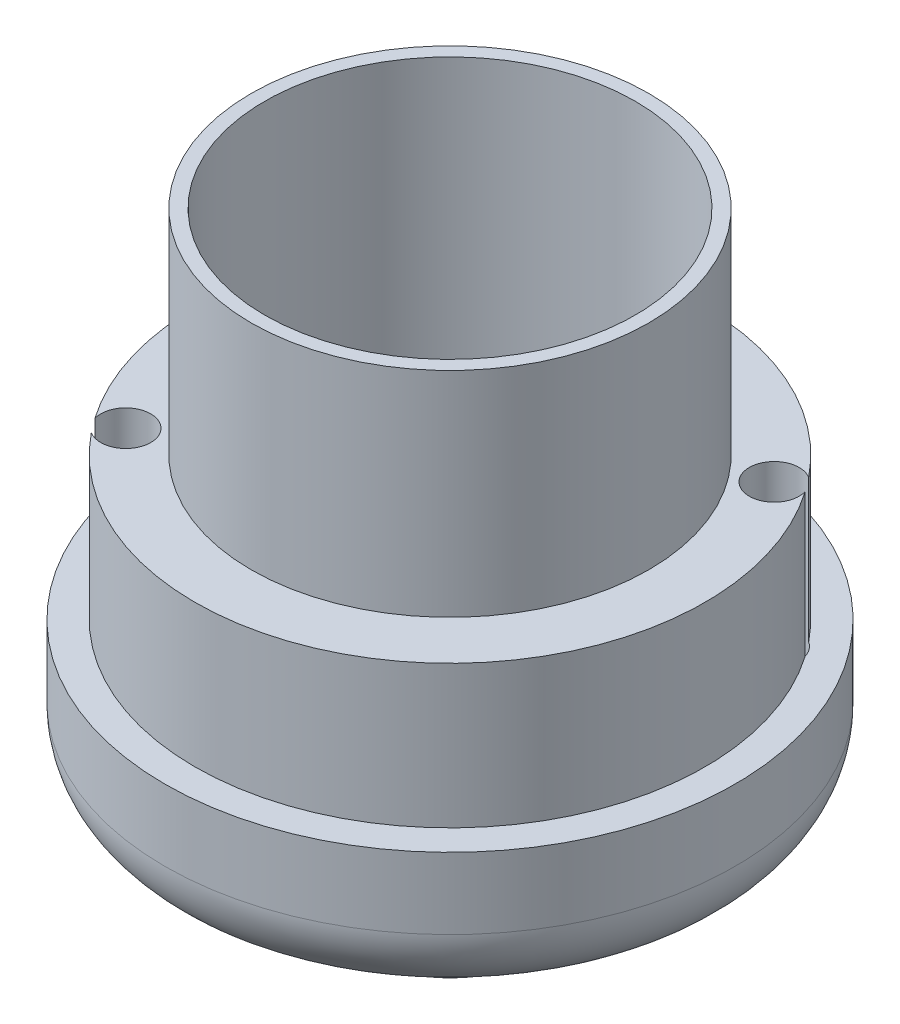
from build123d import *

# Parameters (mm, degrees)
SKETCH1_R               = 17.9
SKETCH1_R_2             = 14.9
BOSS_EXTRUDE1_DEPTH     = 10
SKETCH2_R               = 20
BOSS_EXTRUDE2_DEPTH     = 10
FILLET1_R               = 5
SKETCH3_R               = 1.75
CUT_EXTRUDE1_DEPTH      = 1
CUT_EXTRUDE1_DEPTH_BACK = 332.06387935
CUT_EXTRUDE3_DEPTH      = 3
SKETCH8_R               = 13
BOSS_EXTRUDE3_DEPTH     = 10
SKETCH9_R               = 6.05
BOSS_EXTRUDE4_DEPTH     = 7.5
FILLET2_R               = 2.5
SKETCH11_R              = 2.25
CUT_EXTRUDE4_DEPTH      = 17.5
CUT_EXTRUDE5_DEPTH      = 3.5
SKETCH13_R              = 13.95
SKETCH13_R_2            = 13
BOSS_EXTRUDE5_DEPTH     = 15


with BuildPart() as part:
    # Sketch1 → Boss-Extrude1 (new body)
    with BuildSketch(Plane(origin=(0, -62.195205507, 0), x_dir=(-1, 0, 0), z_dir=(0, -1, 0))):
        with Locations((-0.536002938, -73.600816835)):
            Circle(SKETCH1_R)
        with Locations((-0.536002938, -73.600816835)):
            Circle(SKETCH1_R_2, mode=Mode.SUBTRACT)
    extrude(amount=BOSS_EXTRUDE1_DEPTH)

    # Sketch2 → Boss-Extrude2 (add)
    with BuildSketch(Plane(origin=(0, -72.195205507, 0), x_dir=(-1, 0, 0), z_dir=(0, -1, 0))):
        with Locations((-0.536002938, -73.600816835)):
            Circle(SKETCH2_R)
    extrude(amount=BOSS_EXTRUDE2_DEPTH)

    # Fillet1
    fillet1_edges = [part.edges().sort_by_distance(p)[0] for p in [
        (20.536002938, -82.195205507, 73.600816835),
    ]]
    fillet(fillet1_edges, radius=FILLET1_R)

    # Sketch3 → Cut-Extrude1 (cut, two sides)
    with BuildSketch(Plane(origin=(0, 248.868673843, 0), x_dir=(1, 0, 0), z_dir=(0, 1, 0))) as cut_extrude1_sk:
        with Locations((-12.468535925, -83.344762082)):
            Circle(SKETCH3_R)
        with Locations((13.5405418, -63.856871588)):
            Circle(SKETCH3_R)
    extrude(amount=CUT_EXTRUDE1_DEPTH, mode=Mode.SUBTRACT)
    extrude(cut_extrude1_sk.sketch, amount=-CUT_EXTRUDE1_DEPTH_BACK, mode=Mode.SUBTRACT)

    # Sketch7 → Cut-Extrude3 (cut)
    with BuildSketch(Plane(origin=(0, -82.195205507, 0), x_dir=(-1, 0, 0), z_dir=(0, -1, 0))):
        Polygon((10.564463201, -85.88599021), (13.717267678, -86.264351495), (15.621340402, -83.723123368), (14.372608649, -80.803533955), (11.219804171, -80.425172669), (9.315731448, -82.966400796), align=None)
        Polygon((-15.444614524, -66.398099716), (-12.291810047, -66.776461002), (-10.387737323, -64.235232874), (-11.636469076, -61.315643461), (-14.789273554, -60.937282175), (-16.693346277, -63.478510303), align=None)
    extrude(amount=-CUT_EXTRUDE3_DEPTH, mode=Mode.SUBTRACT)

    # Sketch8 → Boss-Extrude3 (add)
    with BuildSketch(Plane(origin=(0, -62.195205507, 0), x_dir=(1, 0, 0), z_dir=(0, 1, 0))):
        with BuildLine():
            ThreePointArc((16.682247488, -73.600816835), (16.107712715, -69.331968315), (14.424995948, -65.36691823))
            ThreePointArc((14.424995948, -65.36691823), (12.661441741, -65.370041468), (11.790660849, -63.836459442))
            ThreePointArc((11.790660849, -63.836459442), (-8.398445319, -61.676655048), (-11.996595259, -81.659599773))
            ThreePointArc((-11.996595259, -81.659599773), (-11.074190888, -82.287264131), (-10.718535925, -83.344762082))
            ThreePointArc((-10.718535925, -83.344762082), (-10.861687777, -84.037971309), (-11.267723389, -84.617770038))
            ThreePointArc((-11.267723389, -84.617770038), (6.456955614, -88.622252601), (16.682247488, -73.600816835))
        make_face()
        with Locations((0.536002938, -73.600816835)):
            Circle(SKETCH8_R, mode=Mode.SUBTRACT)
    extrude(amount=-BOSS_EXTRUDE3_DEPTH)

    # Sketch9 → Boss-Extrude4 (add)
    with BuildSketch(Plane.XZ.offset(82.195205507)):
        with Locations((0.536002938, 73.600816835)):
            Circle(SKETCH9_R)
    extrude(amount=BOSS_EXTRUDE4_DEPTH)

    # Fillet2
    fillet2_edges = [part.edges().sort_by_distance(p)[0] for p in [
        (-5.513997062, -82.195205507, 73.600816835),
    ]]
    fillet(fillet2_edges, radius=FILLET2_R)

    # Sketch11 → Cut-Extrude4 (cut)
    with BuildSketch(Plane(origin=(0, -89.695205507, 0), x_dir=(-1, 0, 0), z_dir=(0, -1, 0))):
        with Locations((-0.536002938, -73.600816835)):
            Circle(SKETCH11_R)
    extrude(amount=-CUT_EXTRUDE4_DEPTH, mode=Mode.SUBTRACT)

    # Sketch12 → Cut-Extrude5 (cut)
    with BuildSketch(Plane(origin=(0, -72.195205507, 0), x_dir=(1, 0, 0), z_dir=(0, 1, 0))):
        Polygon((2.981769599, -76.818200675), (4.545222407, -73.091412695), (2.099455746, -69.874028855), (-1.909763723, -70.383432996), (-3.473216532, -74.110220976), (-1.027449871, -77.327604816), align=None)
    extrude(amount=-CUT_EXTRUDE5_DEPTH, mode=Mode.SUBTRACT)

    # Sketch13 → Boss-Extrude5 (add)
    with BuildSketch(Plane(origin=(0, -62.195205507, 0), x_dir=(1, 0, 0), z_dir=(0, 1, 0))):
        with Locations((0.536002938, -73.600816835)):
            Circle(SKETCH13_R)
        with Locations((0.536002938, -73.600816835)):
            Circle(SKETCH13_R_2, mode=Mode.SUBTRACT)
    extrude(amount=BOSS_EXTRUDE5_DEPTH)


solid = part.part
